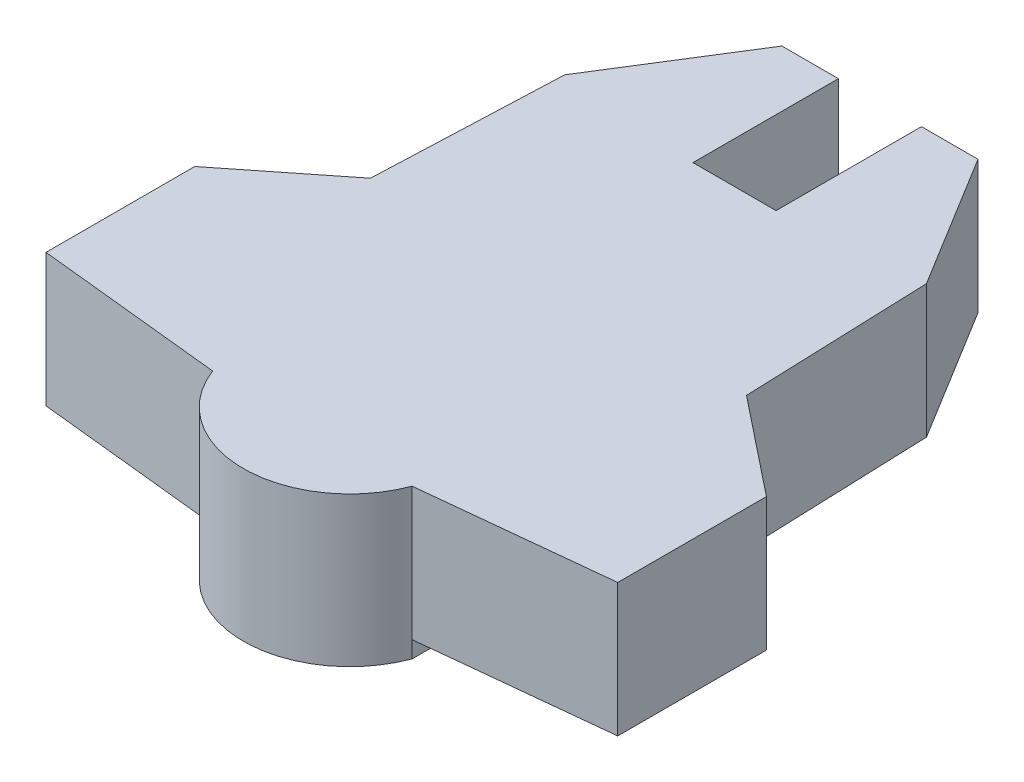
from build123d import *

# Parameters (mm, degrees)
BOSS_EXTRUDE1_DEPTH = 9
SKETCH3_R           = 2.5
BOSS_EXTRUDE2_DEPTH = 6
CUT_EXTRUDE1_DEPTH  = 1


with BuildPart() as part:
    # Sketch2 → Boss-Extrude1 (new body)
    with BuildSketch(Plane(origin=(0, 0, 0), x_dir=(1, 0, 0), z_dir=(0, 1, 0))):
        with BuildLine():
            Line((21.423631539, 59.756571467), (21.423631539, 67.28012571))
            Line((21.423631539, 67.28012571), (27.320471351, 71.956929699))
            Line((27.320471351, 71.956929699), (27.777984785, 83.191426238))
            Line((27.777984785, 83.191426238), (32.810632556, 91.223328742))
            Line((32.810632556, 91.223328742), (36.210632556, 91.223328742))
            Line((36.210632556, 91.223328742), (36.210632556, 82.473328742))
            Line((36.210632556, 82.473328742), (41.210632556, 82.473328742))
            Line((41.210632556, 82.473328742), (41.210632556, 91.223328742))
            Line((41.210632556, 91.223328742), (44.610632556, 91.223328742))
            Line((44.610632556, 91.223328742), (49.541610675, 83.191426238))
            Line((49.541610675, 83.191426238), (49.948289283, 71.956929699))
            Line((49.948289283, 71.956929699), (55.823631539, 67.28012571))
            Line((55.823631539, 67.28012571), (55.823631539, 58.333196339))
            Line((55.823631539, 58.333196339), (44.623631539, 57.163995342))
            ThreePointArc((44.623631539, 57.163995342), (38.623631539, 53.004094152), (32.623631539, 57.163995342))
            Line((32.623631539, 57.163995342), (21.423631539, 58.333196339))
            Line((21.423631539, 58.333196339), (21.423631539, 59.756571467))
        make_face()
    extrude(amount=BOSS_EXTRUDE1_DEPTH)

    # Sketch3 → Boss-Extrude2 (add)
    with BuildSketch(Plane.XZ):
        with Locations((38.670089984, -68.740632333)):
            Circle(SKETCH3_R)
    extrude(amount=BOSS_EXTRUDE2_DEPTH)

    # Sketch4 → Cut-Extrude1 (cut)
    with BuildSketch(Plane.XZ):
        Polygon((32.623631539, -57.163995342), (21.423631539, -58.333196339), (21.423631539, -67.28012571), (27.320471351, -71.956929699), (27.777984785, -83.191426238), (32.810632556, -91.223328742), (36.210632556, -91.223328742), (36.210632556, -82.473328742), (32.623631539, -72.967523608), align=None)
        Polygon((44.623631539, -57.163995342), (44.623631539, -72.967523608), (41.210632556, -82.473328742), (41.210632556, -91.223328742), (44.610632556, -91.223328742), (49.541610675, -83.191426238), (49.948289283, -71.956929699), (55.823631539, -67.28012571), (55.823631539, -58.333196339), align=None)
    extrude(amount=-CUT_EXTRUDE1_DEPTH, mode=Mode.SUBTRACT)


solid = part.part
